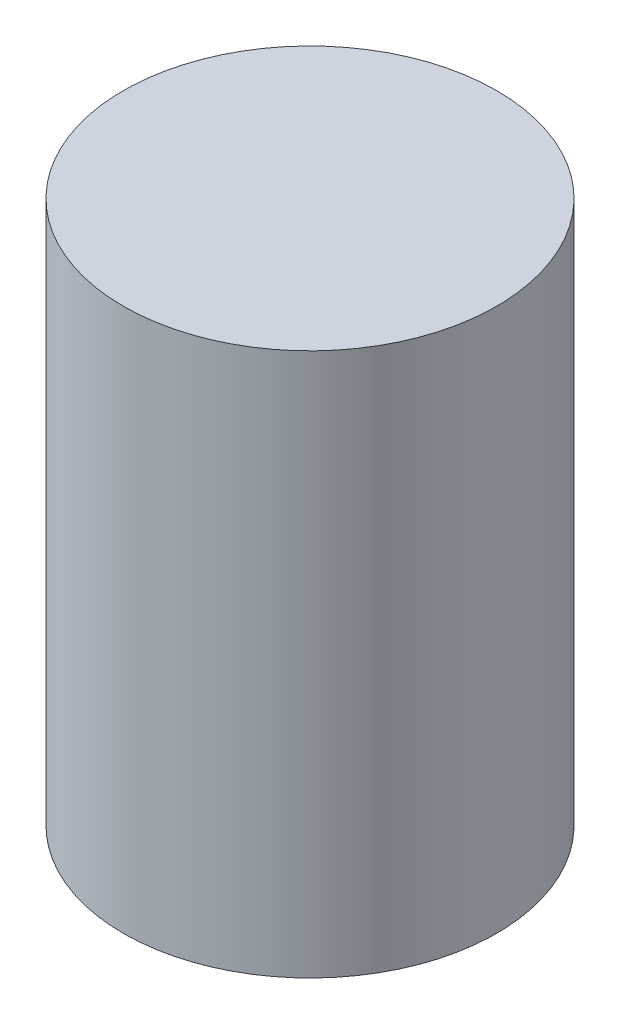
from build123d import *

# Parameters (mm, degrees)
SKETCH1_R           = 13.75
BOSS_EXTRUDE1_DEPTH = 40


with BuildPart() as part:
    # Sketch1 → Boss-Extrude1 (new body)
    with BuildSketch(Plane(origin=(0, 0, 0), x_dir=(1, 0, 0), z_dir=(0, 1, 0))):
        Circle(SKETCH1_R)
    extrude(amount=BOSS_EXTRUDE1_DEPTH)


solid = part.part
